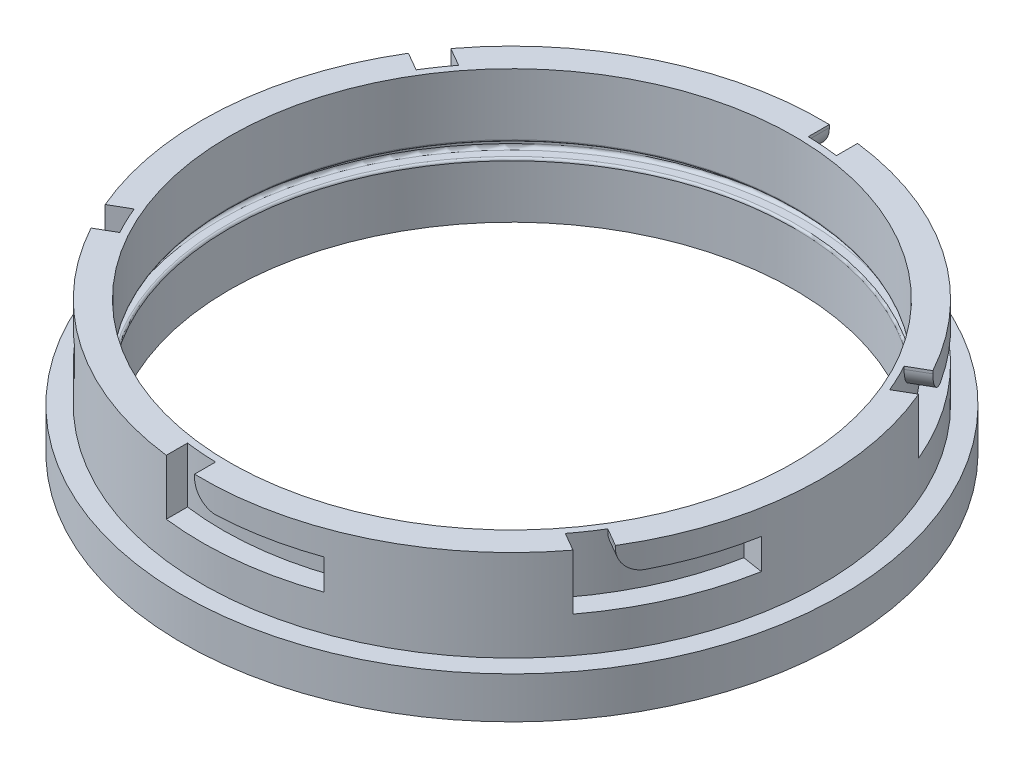
from build123d import *

# Parameters (mm, degrees)
CUT_EXTRUDE1_START       = -12.7
CUT_EXTRUDE1_DEPTH       = 12.7
SKETCH10_W               = 4.827435186
SKETCH10_H               = 6.985
FILLET1_R                = 5.08
CIRPATTERN1_COUNT        = 6
FILLET1_OF_CIRPATTERN1_R = 5.08
FILLET2_R                = 0.762
FILLET3_R                = 0.508


with BuildPart() as part:
    # Sketch1 → Revolve1 (revolve)
    with BuildSketch(Plane.XY):
        Polygon((71.12, 36.5125), (71.12, 15.5575), (75.565, 15.5575), (75.565, 6.0325), (64.77, 6.0325), (64.77, 18.7325), (67.818, 18.7325), (67.818, 21.9075), (64.77, 21.9075), (64.77, 36.5125), align=None)
    revolve(axis=Axis((0, 60.757954545, 0), (0, -1, 0)))

    # Sketch2 → Cut-Extrude1 (cut)
    with BuildSketch(Plane(origin=(0, 36.5125, 0), x_dir=(1, 0, 0), z_dir=(0, 1, 0)).offset(CUT_EXTRUDE1_START)):
        with BuildLine():
            Line((-8.659215821, -70.590880299), (-8.659215821, -65.726040634))
            ThreePointArc((-8.659215821, -65.726040634), (-5.173944735, -66.0917902), (-1.674215821, -66.272855962))
            Line((-1.674215821, -66.272855962), (-1.674215821, -71.100291148))
            ThreePointArc((-1.674215821, -71.100291148), (-5.172990163, -70.931618992), (-8.659215821, -70.590880299))
        make_face()
    cut_extrude1 = extrude(amount=CUT_EXTRUDE1_DEPTH, mode=Mode.SUBTRACT)

    # Cut-Sweep2: sweep along a path in Sketch23
    with BuildLine(Plane(origin=(0, 23.8125, 0), x_dir=(1, 0, 0), z_dir=(0, 1, 0))) as cut_sweep2_path:
        ThreePointArc((-1.674215821, -71.100291148), (11.313422518, -70.214392192), (23.922019276, -66.976050897))
    # Sketch10 → Cut-Sweep2 (sweep, cut)
    with BuildSketch(Plane.ZY.offset(1.674215821)):
        with Locations((68.686573555, 27.305)):
            Rectangle(SKETCH10_W, SKETCH10_H)
    cut_sweep2 = sweep(path=cut_sweep2_path.line, mode=Mode.SUBTRACT)

    # Fillet1
    fillet1_edges = [part.edges().sort_by_distance(p)[0] for p in [
        (-1.674215821, 30.7975, 68.686573555),
    ]]
    fillet(fillet1_edges, radius=FILLET1_R)

    # CirPattern1: Cut-Extrude1, Cut-Sweep2 ×6 about axis
    cirpattern1_axis = Axis((0, 60.757954545, 0), (0, 1, 0))
    add([cut_extrude1.rotate(cirpattern1_axis, i * 360 / CIRPATTERN1_COUNT) for i in range(1, CIRPATTERN1_COUNT)], mode=Mode.SUBTRACT)
    add([cut_sweep2.rotate(cirpattern1_axis, i * 360 / CIRPATTERN1_COUNT) for i in range(1, CIRPATTERN1_COUNT)], mode=Mode.SUBTRACT)

    # Fillet1 of CirPattern1
    fillet1_of_cirpattern1_edges = [part.edges().sort_by_distance(p)[0] for p in [
        (58.647209687, 30.7975, 35.79320021),
        (60.321425508, 30.7975, -32.893373346),
        (1.674215821, 30.7975, -68.686573555),
        (-58.647209687, 30.7975, -35.79320021),
        (-60.321425508, 30.7975, 32.893373346),
    ]]
    fillet(fillet1_of_cirpattern1_edges, radius=FILLET1_OF_CIRPATTERN1_R)

    # Fillet2
    fillet2_edges = [part.edges().sort_by_distance(p)[0] for p in [
        (-67.818, 21.9075, 0),
        (-67.818, 18.7325, 0),
    ]]
    fillet(fillet2_edges, radius=FILLET2_R)

    # Fillet3
    fillet3_edges = [part.edges().sort_by_distance(p)[0] for p in [
        (-64.77, 18.7325, 0),
        (-64.77, 21.9075, 0),
    ]]
    fillet(fillet3_edges, radius=FILLET3_R)


solid = part.part
